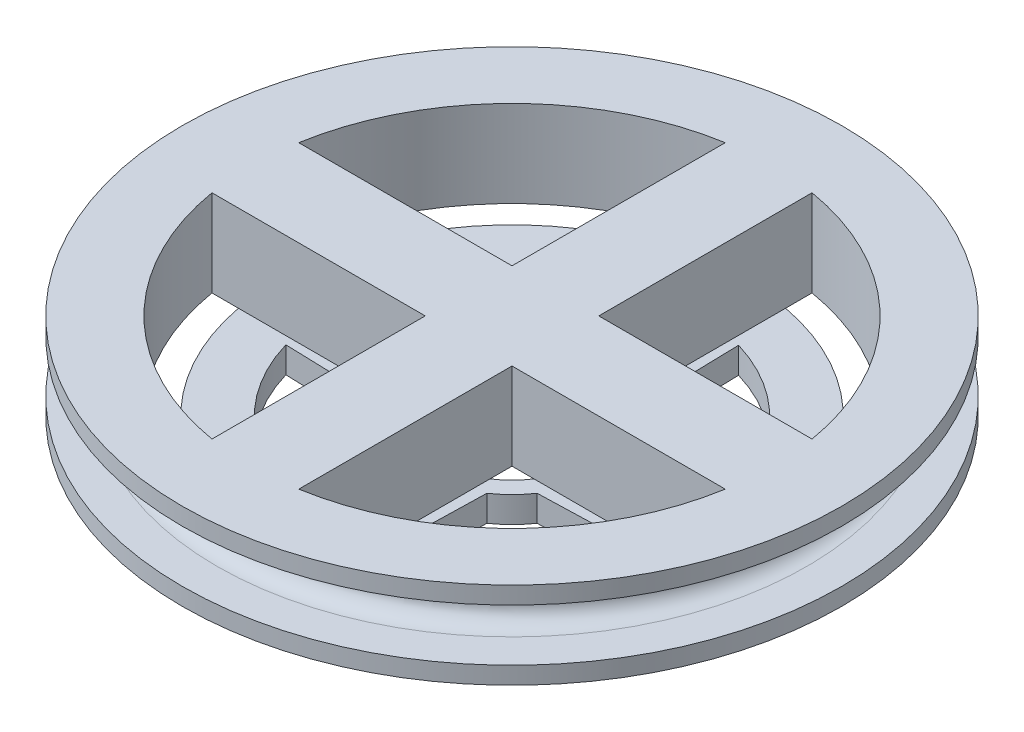
from build123d import *

# Parameters (mm, degrees)
SKETCH1_R            = 25
BOSS_EXTRUDE2_DEPTH  = 3
SKETCH3_R            = 38
BOSS_EXTRUDE4_DEPTH  = 2
SKETCH5_R            = 32
SKETCH5_R_2          = 27
BOSS_EXTRUDE5_DEPTH  = 6
SKETCH6_R            = 5
BOSS_EXTRUDE7_DEPTH  = 6
SKETCH7_R            = 38
BOSS_EXTRUDE9_DEPTH  = 2
FILLET2_R            = 2
FILLET3_R            = 2
FILLET5_R            = 2
SKETCH8_R            = 30
BOSS_EXTRUDE10_DEPTH = 9
CUT_EXTRUDE1_DEPTH   = 10
CUT_EXTRUDE3_DEPTH   = 10


with BuildPart() as part:
    # Sketch1 → Boss-Extrude2 (new body)
    with BuildSketch(Plane(origin=(0, 0, 0), x_dir=(1, 0, 0), z_dir=(0, 1, 0))):
        Circle(SKETCH1_R)
        with BuildLine():
            Line((20, -3.5), (7.537849637, -5))
            ThreePointArc((7.537849637, -5), (6.396060395, -6.396060395), (5, -7.537849637))
            Line((5, -7.537849637), (3.5, -20))
            Line((3.5, -20), (-3.5, -20))
            Line((-3.5, -20), (-5, -7.537849637))
            ThreePointArc((-5, -7.537849637), (-6.396060395, -6.396060395), (-7.537849637, -5))
            Line((-7.537849637, -5), (-20, -3.5))
            Line((-20, -3.5), (-20, 3.5))
            Line((-20, 3.5), (-7.537849637, 5))
            ThreePointArc((-7.537849637, 5), (-6.396060395, 6.396060395), (-5, 7.537849637))
            Line((-5, 7.537849637), (-3.5, 20))
            Line((-3.5, 20), (3.5, 20))
            Line((3.5, 20), (5, 7.537849637))
            ThreePointArc((5, 7.537849637), (6.396060395, 6.396060395), (7.537849637, 5))
            Line((7.537849637, 5), (20, 3.5))
            Line((20, 3.5), (20, -3.5))
        make_face(mode=Mode.SUBTRACT)
    extrude(amount=BOSS_EXTRUDE2_DEPTH)

    # Sketch3 → Boss-Extrude4 (add)
    with BuildSketch(Plane(origin=(0, 3, 0), x_dir=(1, 0, 0), z_dir=(0, 1, 0))):
        Circle(SKETCH3_R)
    extrude(amount=BOSS_EXTRUDE4_DEPTH)

    # Sketch5 → Boss-Extrude5 (add)
    with BuildSketch(Plane(origin=(0, 5, 0), x_dir=(1, 0, 0), z_dir=(0, 1, 0))):
        Circle(SKETCH5_R)
        Circle(SKETCH5_R_2, mode=Mode.SUBTRACT)
    extrude(amount=BOSS_EXTRUDE5_DEPTH)

    # Sketch6 → Boss-Extrude7 (add)
    with BuildSketch(Plane(origin=(0, 5, 0), x_dir=(1, 0, 0), z_dir=(0, 1, 0))):
        Circle(SKETCH6_R)
    extrude(amount=BOSS_EXTRUDE7_DEPTH)

    # Sketch7 → Boss-Extrude9 (add)
    with BuildSketch(Plane(origin=(0, 11, 0), x_dir=(1, 0, 0), z_dir=(0, 1, 0))):
        Circle(SKETCH7_R)
    extrude(amount=BOSS_EXTRUDE9_DEPTH)

    # Fillet2
    fillet2_edges = [part.edges().sort_by_distance(p)[0] for p in [
        (-32, 11, 0),
    ]]
    fillet(fillet2_edges, radius=FILLET2_R)

    # Fillet3
    fillet3_edges = [part.edges().sort_by_distance(p)[0] for p in [
        (-32, 5, 0),
    ]]
    fillet(fillet3_edges, radius=FILLET3_R)

    # Fillet5
    fillet5_edges = [part.edges().sort_by_distance(p)[0] for p in [
        (-25, 3, 0),
    ]]
    fillet(fillet5_edges, radius=FILLET5_R)

    # Sketch8 → Boss-Extrude10 (add)
    with BuildSketch(Plane(origin=(0, 13, 0), x_dir=(1, 0, 0), z_dir=(0, 1, 0))):
        Circle(SKETCH8_R)
    extrude(amount=-BOSS_EXTRUDE10_DEPTH)

    # Sketch9 → Cut-Extrude1 (cut)
    with BuildSketch(Plane(origin=(0, 13, 0), x_dir=(1, 0, 0), z_dir=(0, 1, 0))):
        with BuildLine():
            Line((5, -5), (5, -29.580398915))
            ThreePointArc((5, -29.580398915), (21.213203436, -21.213203436), (29.580398915, -5))
            Line((29.580398915, -5), (5, -5))
        make_face()
        with BuildLine():
            Line((-5, -29.580398915), (-5, -5))
            Line((-5, -5), (-29.580398915, -5))
            ThreePointArc((-29.580398915, -5), (-21.213203436, -21.213203436), (-5, -29.580398915))
        make_face()
        with BuildLine():
            Line((-29.580398915, 5), (-5, 5))
            Line((-5, 5), (-5, 29.580398915))
            ThreePointArc((-5, 29.580398915), (-21.213203436, 21.213203436), (-29.580398915, 5))
        make_face()
        with BuildLine():
            ThreePointArc((29.580398915, 5), (21.213203436, 21.213203436), (5, 29.580398915))
            Line((5, 29.580398915), (5, 5))
            Line((5, 5), (29.580398915, 5))
        make_face()
    extrude(amount=-CUT_EXTRUDE1_DEPTH, mode=Mode.SUBTRACT)

    # Sketch10 → Cut-Extrude3 (cut)
    with BuildSketch(Plane(origin=(0, 3, 0), x_dir=(-1, 0, 0), z_dir=(0, -1, 0))):
        with BuildLine():
            ThreePointArc((-9.154882095, 6.256063873), (-7.840900748, 7.840311015), (-6.256752441, 9.154411518))
            Line((-6.256752441, 9.154411518), (-5.984311052, 20.129282681))
            ThreePointArc((-5.984311052, 20.129282681), (-14.874716269, 14.823724765), (-20.149713772, 5.915152991))
            Line((-20.149713772, 5.915152991), (-9.154882095, 6.256063873))
        make_face()
        with BuildLine():
            Line((5.984311052, 20.129282681), (6.256752441, 9.154411518))
            ThreePointArc((6.256752441, 9.154411518), (7.840900748, 7.840311015), (9.154882095, 6.256063873))
            Line((9.154882095, 6.256063873), (20.149713772, 5.915152991))
            ThreePointArc((20.149713772, 5.915152991), (14.874716269, 14.823724765), (5.984311052, 20.129282681))
        make_face()
        with BuildLine():
            Line((20.149713772, -5.915152991), (9.154882095, -6.256063873))
            ThreePointArc((9.154882095, -6.256063873), (7.840900748, -7.840311015), (6.256752441, -9.154411518))
            Line((6.256752441, -9.154411518), (5.984311052, -20.129282681))
            ThreePointArc((5.984311052, -20.129282681), (14.874716269, -14.823724765), (20.149713772, -5.915152991))
        make_face()
        with BuildLine():
            ThreePointArc((-6.256752441, -9.154411518), (-7.840900748, -7.840311015), (-9.154882095, -6.256063873))
            Line((-9.154882095, -6.256063873), (-20.149713772, -5.915152991))
            ThreePointArc((-20.149713772, -5.915152991), (-14.874716269, -14.823724765), (-5.984311052, -20.129282681))
            Line((-5.984311052, -20.129282681), (-6.256752441, -9.154411518))
        make_face()
    extrude(amount=CUT_EXTRUDE3_DEPTH, mode=Mode.SUBTRACT)


solid = part.part
